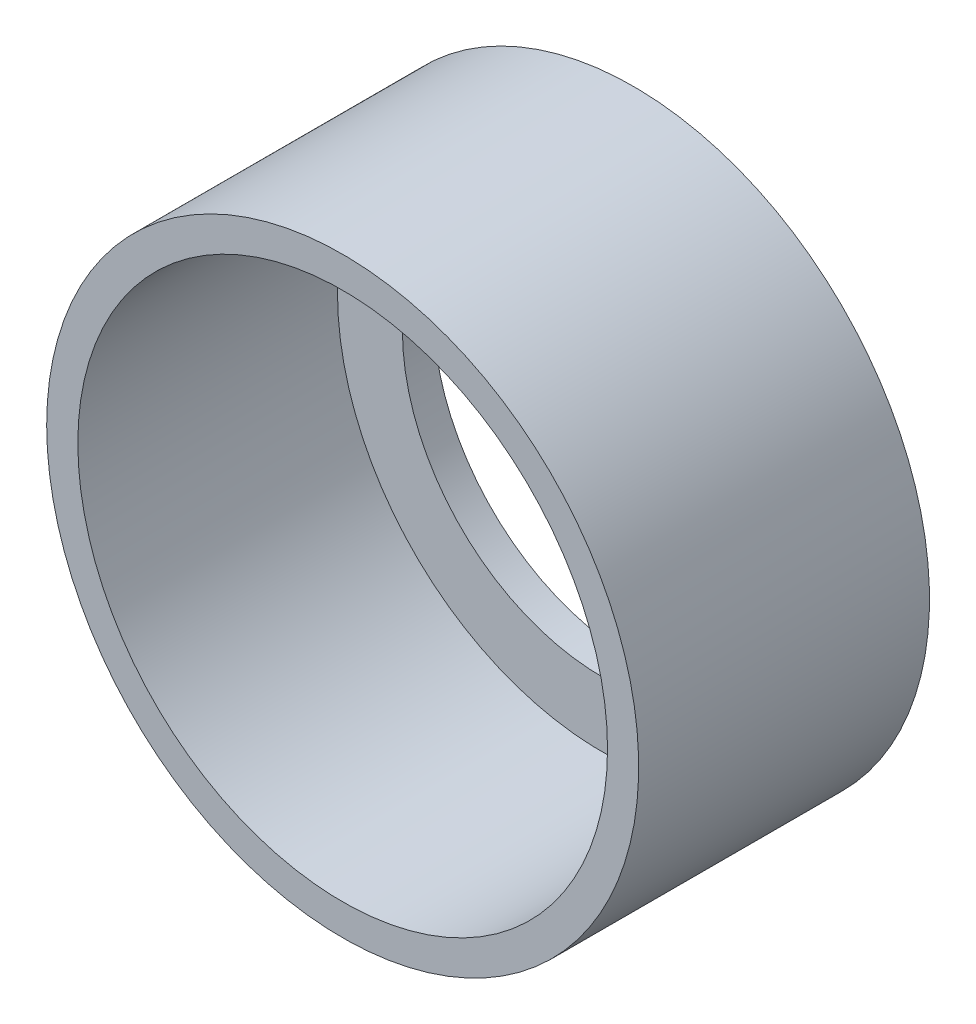
from build123d import *


with BuildPart() as part:
    # Sketch1 → Revolve1 (revolve)
    with BuildSketch(Plane(origin=(0, 0, 0), x_dir=(1, 0, 0), z_dir=(0, 1, 0))):
        Polygon((12.954, 5.425637802), (14.478, 5.425637802), (14.478, 19.649637802), (9.779, 19.649637802), (9.779, 18.125637802), (12.954, 18.125637802), align=None)
    revolve(axis=Axis((0, 0, -10.179008168), (0, 0, 1)))


solid = part.part
